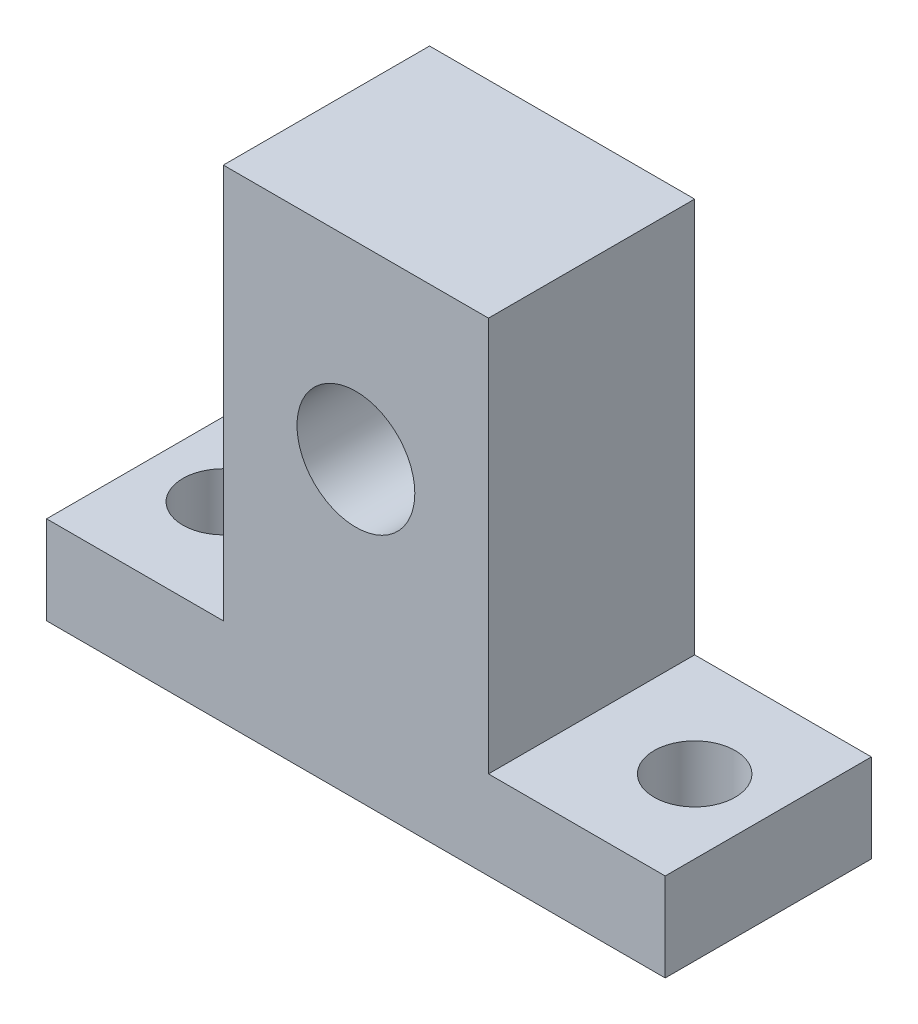
from build123d import *

# Parameters (mm, degrees)
SKETCH1_R           = 4
BOSS_EXTRUDE1_DEPTH = 14
SKETCH2_R           = 2.75
CUT_EXTRUDE1_DEPTH  = 6


with BuildPart() as part:
    # Sketch1 → Boss-Extrude1 (new body)
    with BuildSketch(Plane.XY):
        Polygon((-21, 0), (21, 0), (21, 6), (9, 6), (9, 32.8), (-9, 32.8), (-9, 6), (-21, 6), align=None)
        with Locations((0, 20)):
            Circle(SKETCH1_R, mode=Mode.SUBTRACT)
    extrude(amount=BOSS_EXTRUDE1_DEPTH)

    # Sketch2 → Cut-Extrude1 (cut)
    with BuildSketch(Plane(origin=(0, 6, 0), x_dir=(1, 0, 0), z_dir=(0, 1, 0))):
        with Locations((-16, -7)):
            Circle(SKETCH2_R)
        with Locations((16, -7)):
            Circle(SKETCH2_R)
    extrude(amount=-CUT_EXTRUDE1_DEPTH, mode=Mode.SUBTRACT)


solid = part.part
